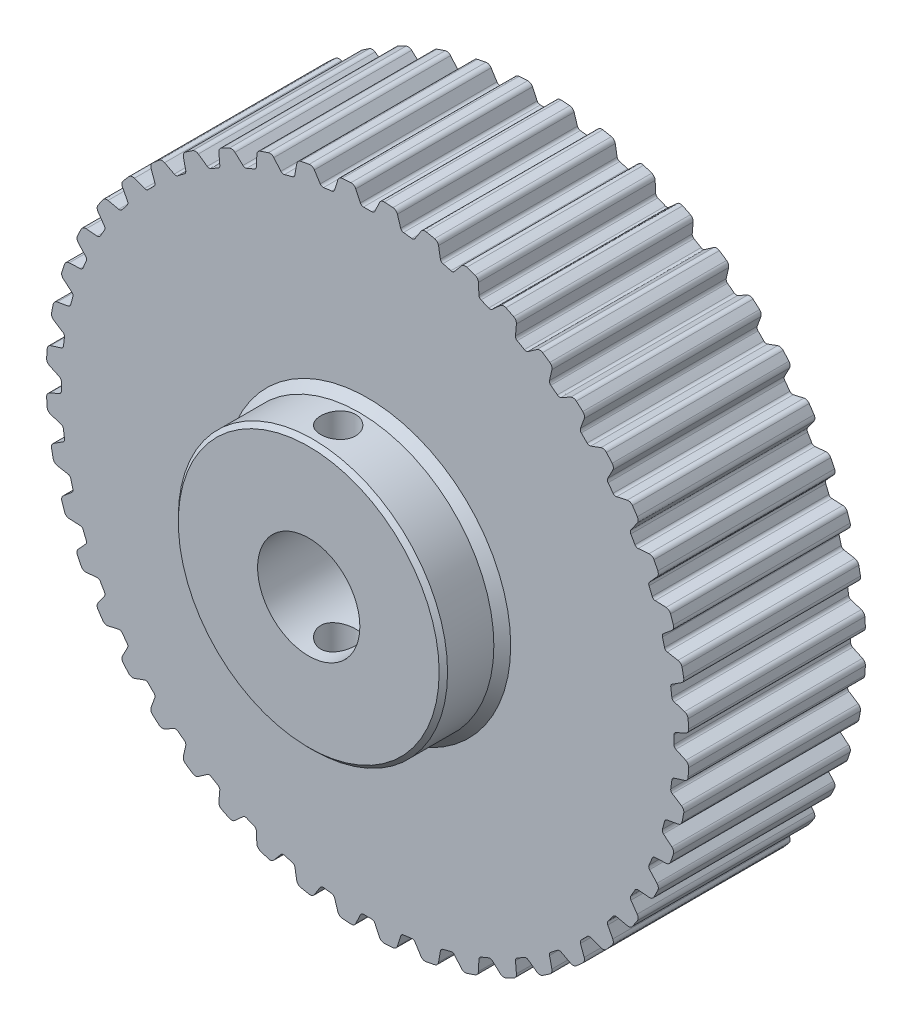
from build123d import *

# Parameters (mm, degrees)
SKETCH1_R                = 38.1972
BOSS_EXTRUDE1_DEPTH      = 21
SKETCH2_R                = 16
BOSS_EXTRUDE2_DEPTH      = 7
SKETCH3_R                = 6.075
CUT_EXTRUDE1_DEPTH       = 61.844491745
CUT_EXTRUDE2_DEPTH       = 58.957330647
FILLET1_R                = 0.4
FILLET2_R                = 0.6
CIRPATTERN1_COUNT        = 48
FILLET1_OF_CIRPATTERN1_R = 0.4
FILLET2_OF_CIRPATTERN1_R = 0.6
SKETCH6_R                = 2.075
CUT_EXTRUDE4_DEPTH       = 25
CHAMFER1_SIZE            = 0.5
CHAMFER2_SIZE            = 1


with BuildPart() as part:
    # Sketch1 → Boss-Extrude1 (new body)
    with BuildSketch(Plane.XY):
        Circle(SKETCH1_R)
    extrude(amount=BOSS_EXTRUDE1_DEPTH)

    # Sketch2 → Boss-Extrude2 (add)
    with BuildSketch(Plane.XY.offset(21)):
        Circle(SKETCH2_R)
    extrude(amount=BOSS_EXTRUDE2_DEPTH)

    # Sketch3 → Cut-Extrude1 (cut, through all)
    with BuildSketch(Plane.XY.offset(28)):
        Circle(SKETCH3_R)
    extrude(amount=-CUT_EXTRUDE1_DEPTH, mode=Mode.SUBTRACT)

    # Sketch4 → Cut-Extrude2 (cut, through all)
    with BuildSketch(Plane.XY.offset(21)):
        with BuildLine():
            Line((-1.59295744, 38.1972), (-0.75, 36.389471937))
            ThreePointArc((-0.75, 36.389471937), (0, 36.3972), (0.75, 36.389471937))
            Line((0.75, 36.389471937), (1.59295744, 38.1972))
            Line((1.59295744, 38.1972), (-1.59295744, 38.1972))
        make_face()
    cut_extrude2 = extrude(amount=-CUT_EXTRUDE2_DEPTH, mode=Mode.SUBTRACT)

    # Fillet1
    fillet1_edges = [part.edges().sort_by_distance(p)[0] for p in [
        (0.75, 36.389471937, 10.5),
        (-0.75, 36.389471937, 10.5),
    ]]
    fillet(fillet1_edges, radius=FILLET1_R)

    # Fillet2
    fillet2_edges = [part.edges().sort_by_distance(p)[0] for p in [
        (1.577756297, 38.164601045, 10.5),
        (-1.577756297, 38.164601045, 10.5),
    ]]
    fillet(fillet2_edges, radius=FILLET2_R)

    # CirPattern1: Cut-Extrude2 ×48 about axis
    cirpattern1_axis = Axis((0, 0, 0), (0, 0, 1))
    for i in range(1, CIRPATTERN1_COUNT):
        add(cut_extrude2.rotate(cirpattern1_axis, i * 360 / CIRPATTERN1_COUNT), mode=Mode.SUBTRACT)

    # Fillet1 of CirPattern1
    fillet1_of_cirpattern1_edges = [part.edges().sort_by_distance(p)[0] for p in [
        (-4.006195563, 36.176049604, 10.5),
        (-5.493362855, 35.980260316, 10.5),
        (-8.693844009, 35.343645033, 10.5),
        (-10.142732748, 34.955416465, 10.5),
        (-13.232738373, 33.906500896, 10.5),
        (-14.618557672, 33.332475747, 10.5),
        (-17.545216916, 31.889207128, 10.5),
        (-18.844255021, 31.139207128, 10.5),
        (-21.557491932, 29.326280184, 10.5),
        (-22.747521942, 28.413138041, 10.5),
        (-25.200912284, 26.261572456, 10.5),
        (-26.261572456, 25.200912284, 10.5),
        (-28.413138041, 22.747521942, 10.5),
        (-29.326280184, 21.557491932, 10.5),
        (-31.139207128, 18.844255021, 10.5),
        (-31.889207128, 17.545216916, 10.5),
        (-33.332475747, 14.618557672, 10.5),
        (-33.906500896, 13.232738373, 10.5),
        (-34.955416465, 10.142732748, 10.5),
        (-35.343645033, 8.693844009, 10.5),
        (-35.980260316, 5.493362855, 10.5),
        (-36.176049604, 4.006195563, 10.5),
        (-36.389471937, 0.75, 10.5),
        (-36.389471937, -0.75, 10.5),
        (-36.176049604, -4.006195563, 10.5),
        (-35.980260316, -5.493362855, 10.5),
        (-35.343645033, -8.693844009, 10.5),
        (-34.955416465, -10.142732748, 10.5),
        (-33.906500896, -13.232738373, 10.5),
        (-33.332475747, -14.618557672, 10.5),
        (-31.889207128, -17.545216916, 10.5),
        (-31.139207128, -18.844255021, 10.5),
        (-29.326280184, -21.557491932, 10.5),
        (-28.413138041, -22.747521942, 10.5),
        (-26.261572456, -25.200912284, 10.5),
        (-25.200912284, -26.261572456, 10.5),
        (-22.747521942, -28.413138041, 10.5),
        (-21.557491932, -29.326280184, 10.5),
        (-18.844255021, -31.139207128, 10.5),
        (-17.545216916, -31.889207128, 10.5),
        (-14.618557672, -33.332475747, 10.5),
        (-13.232738373, -33.906500896, 10.5),
        (-10.142732748, -34.955416465, 10.5),
        (-8.693844009, -35.343645033, 10.5),
        (-5.493362855, -35.980260316, 10.5),
        (-4.006195563, -36.176049604, 10.5),
        (-0.75, -36.389471937, 10.5),
        (0.75, -36.389471937, 10.5),
        (4.006195563, -36.176049604, 10.5),
        (5.493362855, -35.980260316, 10.5),
        (8.693844009, -35.343645033, 10.5),
        (10.142732748, -34.955416465, 10.5),
        (13.232738373, -33.906500896, 10.5),
        (14.618557672, -33.332475747, 10.5),
        (17.545216916, -31.889207128, 10.5),
        (18.844255021, -31.139207128, 10.5),
        (21.557491932, -29.326280184, 10.5),
        (22.747521942, -28.413138041, 10.5),
        (25.200912284, -26.261572456, 10.5),
        (26.261572456, -25.200912284, 10.5),
        (28.413138041, -22.747521942, 10.5),
        (29.326280184, -21.557491932, 10.5),
        (31.139207128, -18.844255021, 10.5),
        (31.889207128, -17.545216916, 10.5),
        (33.332475747, -14.618557672, 10.5),
        (33.906500896, -13.232738373, 10.5),
        (34.955416465, -10.142732748, 10.5),
        (35.343645033, -8.693844009, 10.5),
        (35.980260316, -5.493362855, 10.5),
        (36.176049604, -4.006195563, 10.5),
        (36.389471937, -0.75, 10.5),
        (36.389471937, 0.75, 10.5),
        (36.176049604, 4.006195563, 10.5),
        (35.980260316, 5.493362855, 10.5),
        (35.343645033, 8.693844009, 10.5),
        (34.955416465, 10.142732748, 10.5),
        (33.906500896, 13.232738373, 10.5),
        (33.332475747, 14.618557672, 10.5),
        (31.889207128, 17.545216916, 10.5),
        (31.139207128, 18.844255021, 10.5),
        (29.326280184, 21.557491932, 10.5),
        (28.413138041, 22.747521942, 10.5),
        (26.261572456, 25.200912284, 10.5),
        (25.200912284, 26.261572456, 10.5),
        (22.747521942, 28.413138041, 10.5),
        (21.557491932, 29.326280184, 10.5),
        (18.844255021, 31.139207128, 10.5),
        (17.545216916, 31.889207128, 10.5),
        (14.618557672, 33.332475747, 10.5),
        (13.232738373, 33.906500896, 10.5),
        (10.142732748, 34.955416465, 10.5),
        (8.693844009, 35.343645033, 10.5),
        (5.493362855, 35.980260316, 10.5),
        (4.006195563, 36.176049604, 10.5),
    ]]
    fillet(fillet1_of_cirpattern1_edges, radius=FILLET1_OF_CIRPATTERN1_R)

    # Fillet2 of CirPattern1
    fillet2_of_cirpattern1_edges = [part.edges().sort_by_distance(p)[0] for p in [
        (-3.417221679, 38.044036114, 10.5),
        (-6.545738425, 37.63215907, 10.5),
        (-8.353730044, 37.272527177, 10.5),
        (-11.401721154, 36.455820421, 10.5),
        (-13.147303772, 35.863274967, 10.5),
        (-16.062617273, 34.655712576, 10.5),
        (-17.715923488, 33.840392179, 10.5),
        (-20.448677557, 32.262635881, 10.5),
        (-21.981418841, 31.238490898, 10.5),
        (-24.484855298, 29.317536542, 10.5),
        (-25.870806023, 28.102090377, 10.5),
        (-28.102090377, 25.870806023, 10.5),
        (-29.317536542, 24.484855298, 10.5),
        (-31.238490898, 21.981418841, 10.5),
        (-32.262635881, 20.448677557, 10.5),
        (-33.840392179, 17.715923488, 10.5),
        (-34.655712576, 16.062617273, 10.5),
        (-35.863274967, 13.147303772, 10.5),
        (-36.455820421, 11.401721154, 10.5),
        (-37.272527177, 8.353730044, 10.5),
        (-37.63215907, 6.545738425, 10.5),
        (-38.044036114, 3.417221679, 10.5),
        (-38.164601045, 1.577756297, 10.5),
        (-38.164601045, -1.577756297, 10.5),
        (-38.044036114, -3.417221679, 10.5),
        (-37.63215907, -6.545738425, 10.5),
        (-37.272527177, -8.353730044, 10.5),
        (-36.455820421, -11.401721154, 10.5),
        (-35.863274967, -13.147303772, 10.5),
        (-34.655712576, -16.062617273, 10.5),
        (-33.840392179, -17.715923488, 10.5),
        (-32.262635881, -20.448677557, 10.5),
        (-31.238490898, -21.981418841, 10.5),
        (-29.317536542, -24.484855298, 10.5),
        (-28.102090377, -25.870806023, 10.5),
        (-25.870806023, -28.102090377, 10.5),
        (-24.484855298, -29.317536542, 10.5),
        (-21.981418841, -31.238490898, 10.5),
        (-20.448677557, -32.262635881, 10.5),
        (-17.715923488, -33.840392179, 10.5),
        (-16.062617273, -34.655712576, 10.5),
        (-13.147303772, -35.863274967, 10.5),
        (-11.401721154, -36.455820421, 10.5),
        (-8.353730044, -37.272527177, 10.5),
        (-6.545738425, -37.63215907, 10.5),
        (-3.417221679, -38.044036114, 10.5),
        (-1.577756297, -38.164601045, 10.5),
        (1.577756297, -38.164601045, 10.5),
        (3.417221679, -38.044036114, 10.5),
        (6.545738425, -37.63215907, 10.5),
        (8.353730044, -37.272527177, 10.5),
        (11.401721154, -36.455820421, 10.5),
        (13.147303772, -35.863274967, 10.5),
        (16.062617273, -34.655712576, 10.5),
        (17.715923488, -33.840392179, 10.5),
        (20.448677557, -32.262635881, 10.5),
        (21.981418841, -31.238490898, 10.5),
        (24.484855298, -29.317536542, 10.5),
        (25.870806023, -28.102090377, 10.5),
        (28.102090377, -25.870806023, 10.5),
        (29.317536542, -24.484855298, 10.5),
        (31.238490898, -21.981418841, 10.5),
        (32.262635881, -20.448677557, 10.5),
        (33.840392179, -17.715923488, 10.5),
        (34.655712576, -16.062617273, 10.5),
        (35.863274967, -13.147303772, 10.5),
        (36.455820421, -11.401721154, 10.5),
        (37.272527177, -8.353730044, 10.5),
        (37.63215907, -6.545738425, 10.5),
        (38.044036114, -3.417221679, 10.5),
        (38.164601045, -1.577756297, 10.5),
        (38.164601045, 1.577756297, 10.5),
        (38.044036114, 3.417221679, 10.5),
        (37.63215907, 6.545738425, 10.5),
        (37.272527177, 8.353730044, 10.5),
        (36.455820421, 11.401721154, 10.5),
        (35.863274967, 13.147303772, 10.5),
        (34.655712576, 16.062617273, 10.5),
        (33.840392179, 17.715923488, 10.5),
        (32.262635881, 20.448677557, 10.5),
        (31.238490898, 21.981418841, 10.5),
        (29.317536542, 24.484855298, 10.5),
        (28.102090377, 25.870806023, 10.5),
        (25.870806023, 28.102090377, 10.5),
        (24.484855298, 29.317536542, 10.5),
        (21.981418841, 31.238490898, 10.5),
        (20.448677557, 32.262635881, 10.5),
        (17.715923488, 33.840392179, 10.5),
        (16.062617273, 34.655712576, 10.5),
        (13.147303772, 35.863274967, 10.5),
        (11.401721154, 36.455820421, 10.5),
        (8.353730044, 37.272527177, 10.5),
        (6.545738425, 37.63215907, 10.5),
        (3.417221679, 38.044036114, 10.5),
    ]]
    fillet(fillet2_of_cirpattern1_edges, radius=FILLET2_OF_CIRPATTERN1_R)

    # Sketch6 → Cut-Extrude4 (cut, symmetric)
    with BuildSketch(Plane(origin=(0, 0, 0), x_dir=(1, 0, 0), z_dir=(0, 1, 0))):
        with Locations((0, -24.5)):
            Circle(SKETCH6_R)
    extrude(amount=CUT_EXTRUDE4_DEPTH, both=True, mode=Mode.SUBTRACT)

    # Chamfer1
    chamfer1_edges = [part.edges().sort_by_distance(p)[0] for p in [
        (-16, 0, 28),
    ]]
    chamfer(chamfer1_edges, length=CHAMFER1_SIZE)

    # Chamfer2
    chamfer2_edges = [part.edges().sort_by_distance(p)[0] for p in [
        (-16, 0, 21),
    ]]
    chamfer(chamfer2_edges, length=CHAMFER2_SIZE)


solid = part.part
